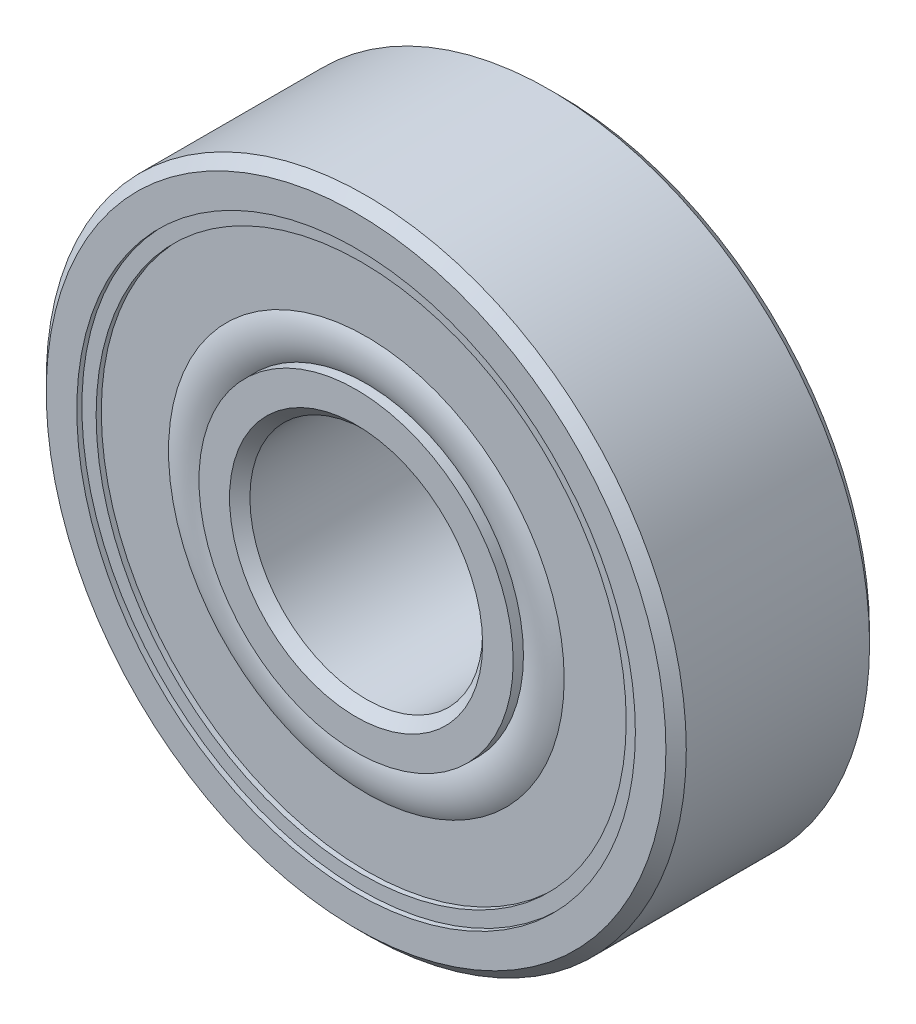
from build123d import *

# Parameters (mm, degrees)
CIRPATTERN1_COUNT = 7


with BuildPart() as part:
    # Sketch3 → Revolve1 (revolve)
    with BuildSketch(Plane(origin=(0, 0, 0), x_dir=(0, 0, -1), z_dir=(1, 0, 0))):
        with BuildLine():
            Line((-3.5, 10.65), (-3.5, 9.6))
            Line((-3.5, 9.6), (-1.555555556, 9.6))
            ThreePointArc((-1.555555556, 9.6), (0, 10.113379629), (1.555555556, 9.6))
            Line((1.555555556, 9.6), (3.5, 9.6))
            Line((3.5, 9.6), (3.5, 10.65))
            Line((3.5, 10.65), (3.15, 11))
            Line((3.15, 11), (-3.15, 11))
            Line((-3.15, 11), (-3.5, 10.65))
        make_face()
        with BuildLine():
            Line((-3.5, 4.35), (-3.5, 5.4))
            Line((-3.5, 5.4), (-1.555555556, 5.4))
            ThreePointArc((-1.555555556, 5.4), (0, 4.886620371), (1.555555556, 5.4))
            Line((1.555555556, 5.4), (3.5, 5.4))
            Line((3.5, 5.4), (3.5, 4.35))
            Line((3.5, 4.35), (3.15, 4))
            Line((3.15, 4), (-3.15, 4))
            Line((-3.15, 4), (-3.5, 4.35))
        make_face()
    revolve(axis=Axis((0, 0, 3.5), (0, 0, -1)))


with BuildPart() as body_2:
    # Sketch4 → Revolve2 (revolve)
    with BuildSketch(Plane(origin=(0, 0, 0), x_dir=(0, 0, -1), z_dir=(1, 0, 0))):
        with BuildLine():
            Line((-2.613379629, 7.5), (2.613379629, 7.5))
            ThreePointArc((2.613379629, 7.5), (0, 10.113379629), (-2.613379629, 7.5))
        make_face()
    revolve(axis=Axis((0, 7.5, 2.613379629), (0, 0, -1)))


with BuildPart() as cirpattern1_1:
    # CirPattern1: pattern copy
    add(body_2.part.rotate(Axis((0, 0, 0), (0, 0, 1)), 1 * 360 / CIRPATTERN1_COUNT))


with BuildPart() as cirpattern1_2:
    # CirPattern1: pattern copy
    add(body_2.part.rotate(Axis((0, 0, 0), (0, 0, 1)), 2 * 360 / CIRPATTERN1_COUNT))


with BuildPart() as cirpattern1_3:
    # CirPattern1: pattern copy
    add(body_2.part.rotate(Axis((0, 0, 0), (0, 0, 1)), 3 * 360 / CIRPATTERN1_COUNT))


with BuildPart() as cirpattern1_4:
    # CirPattern1: pattern copy
    add(body_2.part.rotate(Axis((0, 0, 0), (0, 0, 1)), 4 * 360 / CIRPATTERN1_COUNT))


with BuildPart() as cirpattern1_5:
    # CirPattern1: pattern copy
    add(body_2.part.rotate(Axis((0, 0, 0), (0, 0, 1)), 5 * 360 / CIRPATTERN1_COUNT))


with BuildPart() as cirpattern1_6:
    # CirPattern1: pattern copy
    add(body_2.part.rotate(Axis((0, 0, 0), (0, 0, 1)), 6 * 360 / CIRPATTERN1_COUNT))


with BuildPart() as body_9:
    # Sketch5 → Revolve3 (revolve)
    with BuildSketch(Plane(origin=(0, 0, 0), x_dir=(0, 0, -1), z_dir=(1, 0, 0))):
        with BuildLine():
            Line((-3.325, 9.6), (-2.613379629, 9.6))
            Line((-2.613379629, 9.6), (-2.613379629, 5.4))
            Line((-2.613379629, 5.4), (-3.147094907, 5.4))
            ThreePointArc((-3.147094907, 5.4), (-3.325, 6.1), (-3.147094907, 6.8))
            Line((-3.147094907, 6.8), (-3.147094907, 9.11))
            Line((-3.147094907, 9.11), (-3.325, 9.11))
            Line((-3.325, 9.11), (-3.325, 9.6))
        make_face()
        with BuildLine():
            Line((3.147094907, 5.4), (2.613379629, 5.4))
            Line((2.613379629, 5.4), (2.613379629, 9.6))
            Line((2.613379629, 9.6), (3.325, 9.6))
            Line((3.325, 9.6), (3.325, 9.11))
            Line((3.325, 9.11), (3.147094907, 9.11))
            Line((3.147094907, 9.11), (3.147094907, 6.8))
            ThreePointArc((3.147094907, 6.8), (3.325, 6.1), (3.147094907, 5.4))
        make_face()
    revolve(axis=Axis((0, 0, 3.5), (0, 0, -1)))


solid = Compound([part.part, body_2.part, cirpattern1_1.part, cirpattern1_2.part, cirpattern1_3.part, cirpattern1_4.part, cirpattern1_5.part, cirpattern1_6.part, body_9.part])
